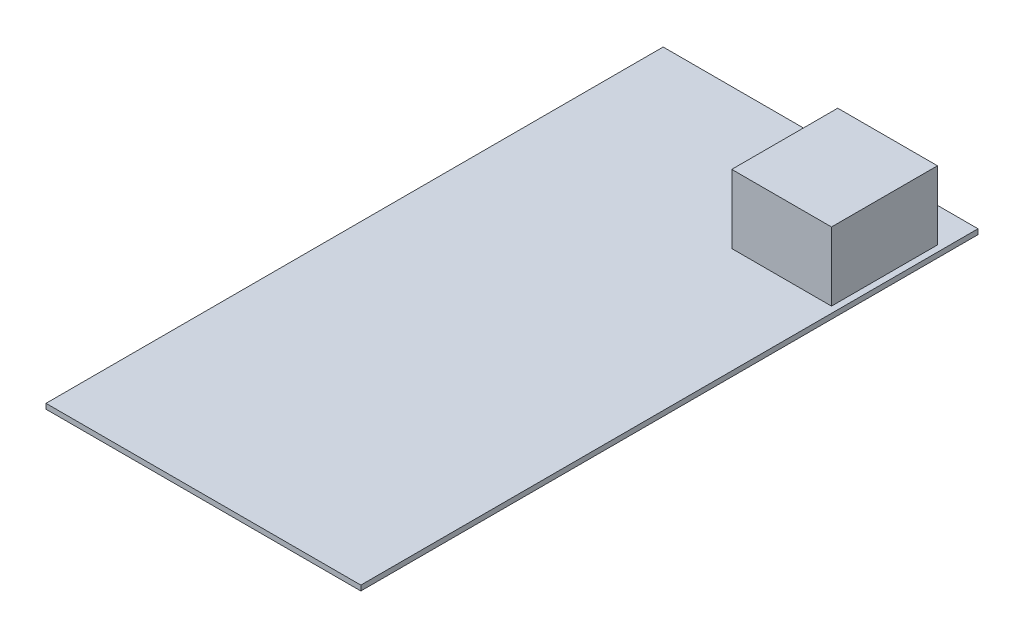
from build123d import *

# Parameters (mm, degrees)
SKETCH1_W      = 101
SKETCH1_H      = 198
HV_BOARD_DEPTH = 1.65
SKETCH2_W      = 32
SKETCH2_H      = 34
INDUCTOR_DEPTH = 22


with BuildPart() as part:
    # Sketch1 → HV Board (new body)
    with BuildSketch(Plane(origin=(0, 0, 0), x_dir=(1, 0, 0), z_dir=(0, 1, 0))):
        Rectangle(SKETCH1_W, SKETCH1_H)
    extrude(amount=HV_BOARD_DEPTH)

    # Sketch2 → Inductor (add)
    with BuildSketch(Plane(origin=(0, 1.65, 0), x_dir=(1, 0, 0), z_dir=(0, 1, 0))):
        with Locations((32.5, 71)):
            Rectangle(SKETCH2_W, SKETCH2_H)
    extrude(amount=INDUCTOR_DEPTH)


solid = part.part
